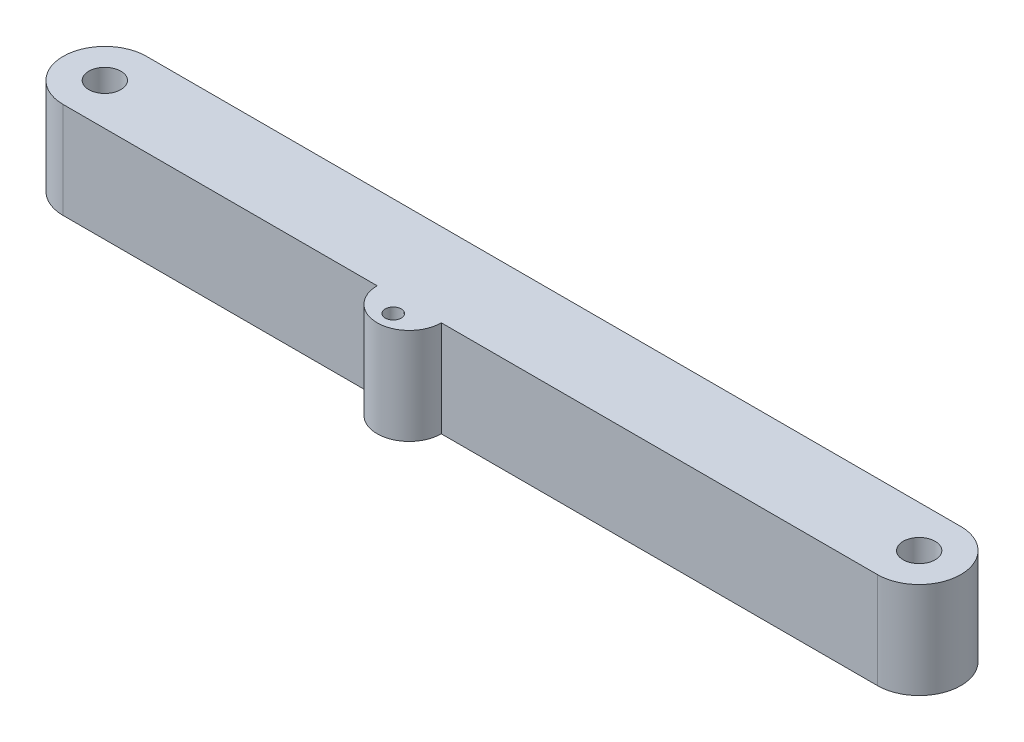
from build123d import *

# Parameters (mm, degrees)
SKETCH1_R           = 3.175
BOSS_EXTRUDE1_DEPTH = 19.05
SKETCH2_R           = 6.35
SKETCH2_R_2         = 1.5875
BOSS_EXTRUDE2_DEPTH = 19.05


with BuildPart() as part:
    # Sketch1 → Boss-Extrude1 (new body)
    with BuildSketch(Plane(origin=(0, 0, 0), x_dir=(1, 0, 0), z_dir=(0, 1, 0))):
        with BuildLine():
            Line((-80.645, -8.255), (80.645, -8.255))
            ThreePointArc((80.645, -8.255), (88.9, 0), (80.645, 8.255))
            Line((80.645, 8.255), (-80.645, 8.255))
            ThreePointArc((-80.645, 8.255), (-88.9, 0), (-80.645, -8.255))
        make_face()
        with Locations((-80.645, 0)):
            Circle(SKETCH1_R, mode=Mode.SUBTRACT)
        with Locations((80.645, 0)):
            Circle(SKETCH1_R, mode=Mode.SUBTRACT)
    extrude(amount=BOSS_EXTRUDE1_DEPTH)

    # Sketch2 → Boss-Extrude2 (add)
    with BuildSketch(Plane(origin=(0, 19.05, 0), x_dir=(1, 0, 0), z_dir=(0, 1, 0))):
        with Locations((-12.0976136, -8.255)):
            Circle(SKETCH2_R)
        with Locations((-12.0976136, -11.43)):
            Circle(SKETCH2_R_2, mode=Mode.SUBTRACT)
    extrude(amount=-BOSS_EXTRUDE2_DEPTH)


solid = part.part
